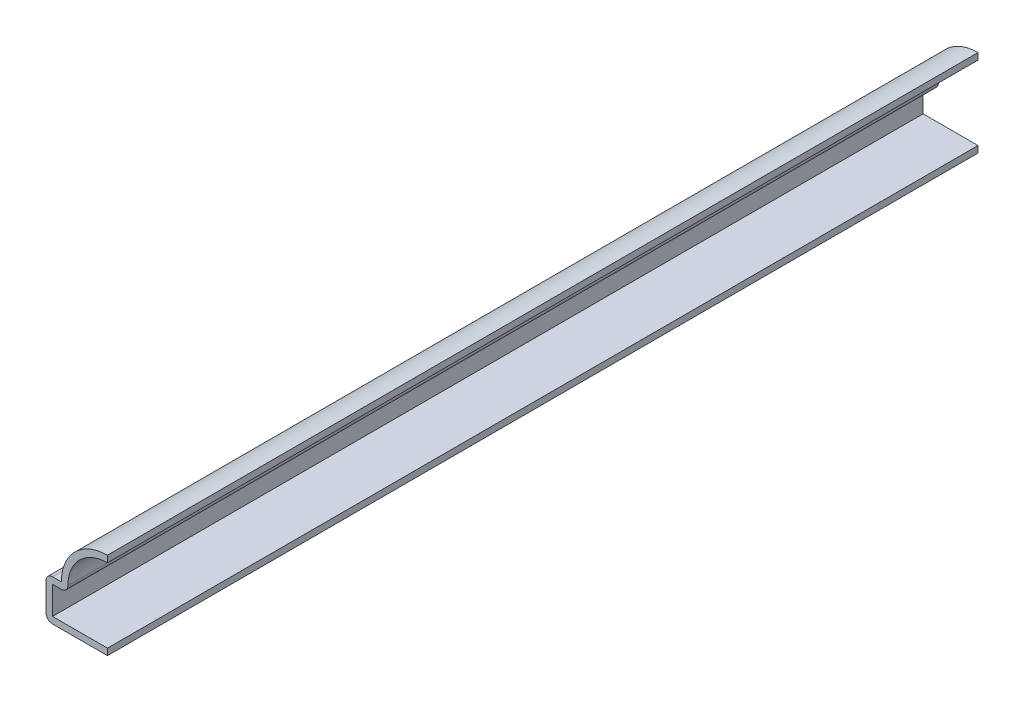
from build123d import *

# Parameters (mm, degrees)
EXTRUDE_THIN1_DEPTH = 134.9375
FILLET1_R           = 1.016


with BuildPart() as part:
    # Sketch1 → Extrude-Thin1 (new body)
    with BuildSketch(Plane.XY):
        with BuildLine():
            Line((0, 0), (-9.525, 0))
            Line((-9.525, 0), (-9.525, 6.35))
            Line((-9.525, 6.35), (-7.14375, 6.35))
            ThreePointArc((-7.14375, 6.35), (-5.051394068, 11.401394068), (0, 13.49375))
            Line((0, 13.49375), (0, 12.47775))
            ThreePointArc((0, 12.47775), (-4.678413944, 10.30749454), (-6.042935054, 5.334))
            Line((-6.042935054, 5.334), (-8.509, 5.334))
            Line((-8.509, 5.334), (-8.509, 1.016))
            Line((-8.509, 1.016), (0, 1.016))
            Line((0, 1.016), (0, 0))
        make_face()
    extrude(amount=-EXTRUDE_THIN1_DEPTH)

    # Fillet1
    fillet1_edges = [part.edges().sort_by_distance(p)[0] for p in [
        (-6.042935054, 5.334, -67.46875),
        (-9.525, 0, -67.46875),
        (-9.525, 6.35, -67.46875),
    ]]
    fillet(fillet1_edges, radius=FILLET1_R)


solid = part.part
